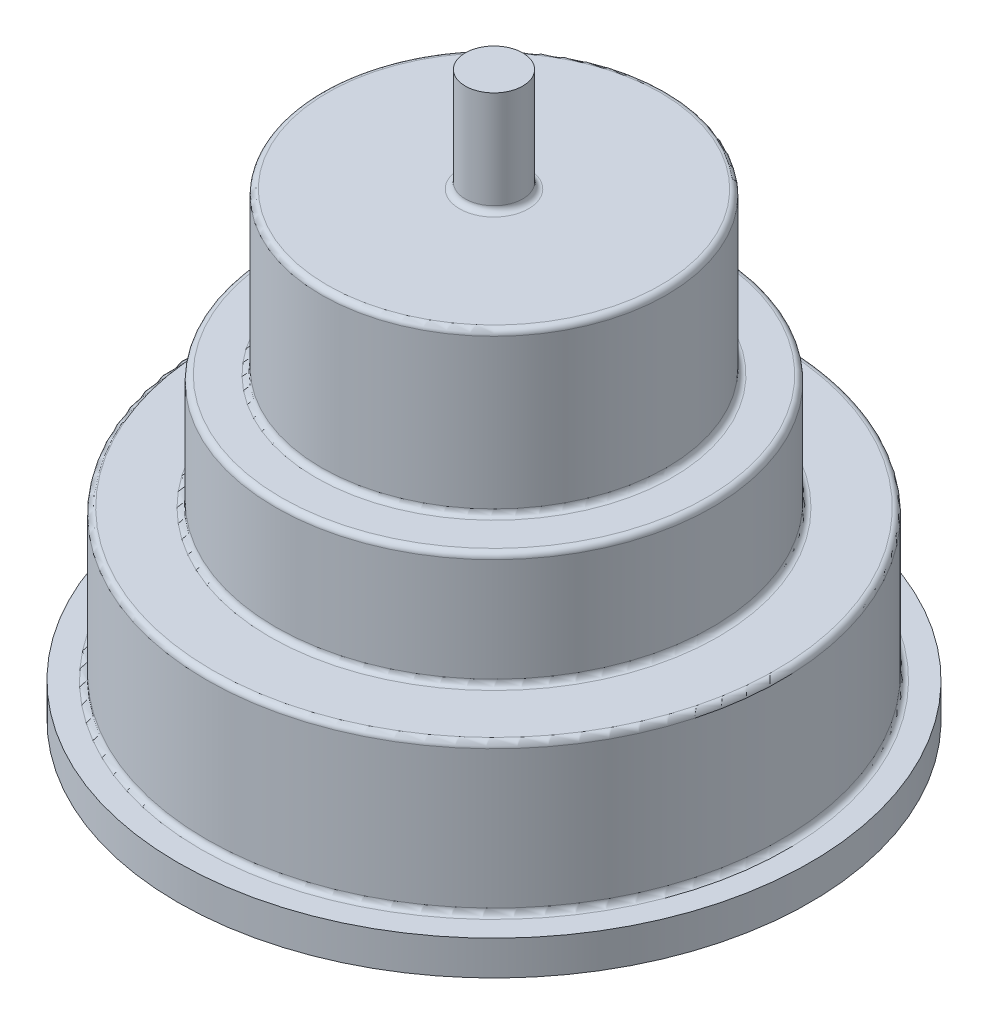
from build123d import *

# Parameters (mm, degrees)
SKETCH1_R             = 27.5
BOSS_EXTRUDE1_DEPTH   = 3
SKETCH2_R             = 25
BOSS_EXTRUDE2_DEPTH   = 23
SKETCH7_R             = 15
BOSS_EXTRUDE4_DEPTH   = 14
SKETCH3_R             = 2.5
BOSS_EXTRUDE3_DEPTH   = 9
M4_TAPPED_HOLE1_D     = 3.3
M4_TAPPED_HOLE1_DEPTH = 11
M4_TAPPED_HOLE1_TIP   = 0.991420021
SKETCH8_R             = 25
SKETCH8_R_2           = 19
CUT_EXTRUDE2_DEPTH    = 10
FILLET2_R             = 0.5


with BuildPart() as part:
    # Sketch1 → Boss-Extrude1 (new body)
    with BuildSketch(Plane(origin=(0, 0, 0), x_dir=(1, 0, 0), z_dir=(0, 1, 0))):
        Circle(SKETCH1_R)
    extrude(amount=BOSS_EXTRUDE1_DEPTH)

    # Sketch2 → Boss-Extrude2 (add)
    with BuildSketch(Plane(origin=(0, 3, 0), x_dir=(1, 0, 0), z_dir=(0, 1, 0))):
        Circle(SKETCH2_R)
    extrude(amount=BOSS_EXTRUDE2_DEPTH)

    # Sketch7 → Boss-Extrude4 (add)
    with BuildSketch(Plane(origin=(0, 26, 0), x_dir=(1, 0, 0), z_dir=(0, 1, 0))):
        Circle(SKETCH7_R)
    extrude(amount=BOSS_EXTRUDE4_DEPTH)

    # Sketch3 → Boss-Extrude3 (add)
    with BuildSketch(Plane(origin=(0, 40, 0), x_dir=(1, 0, 0), z_dir=(0, 1, 0))):
        Circle(SKETCH3_R)
    extrude(amount=BOSS_EXTRUDE3_DEPTH)

    # M4 Tapped Hole1
    with Locations(Plane(origin=(0, 0, 0), x_dir=(-1, 0, 0), z_dir=(0, -1, 0))):
        with Locations((0, -17), (-17, 0), (0, 17), (17, 0)):
            Hole(M4_TAPPED_HOLE1_D / 2, depth=M4_TAPPED_HOLE1_DEPTH)
            with Locations((0, 0, -(M4_TAPPED_HOLE1_DEPTH + M4_TAPPED_HOLE1_TIP / 2))):  # 118° drill point
                Cone(0, M4_TAPPED_HOLE1_D / 2, M4_TAPPED_HOLE1_TIP, mode=Mode.SUBTRACT)

    # Sketch8 → Cut-Extrude2 (cut)
    with BuildSketch(Plane(origin=(0, 26, 0), x_dir=(1, 0, 0), z_dir=(0, 1, 0))):
        Circle(SKETCH8_R)
        Circle(SKETCH8_R_2, mode=Mode.SUBTRACT)
    extrude(amount=-CUT_EXTRUDE2_DEPTH, mode=Mode.SUBTRACT)

    # Fillet2
    fillet2_edges = [part.edges().sort_by_distance(p)[0] for p in [
        (-15, 26, 0),
        (-15, 40, 0),
        (-2.5, 40, 0),
        (-19, 16, 0),
        (-19, 26, 0),
        (-25, 16, 0),
        (-25, 3, 0),
    ]]
    fillet(fillet2_edges, radius=FILLET2_R)


solid = part.part
